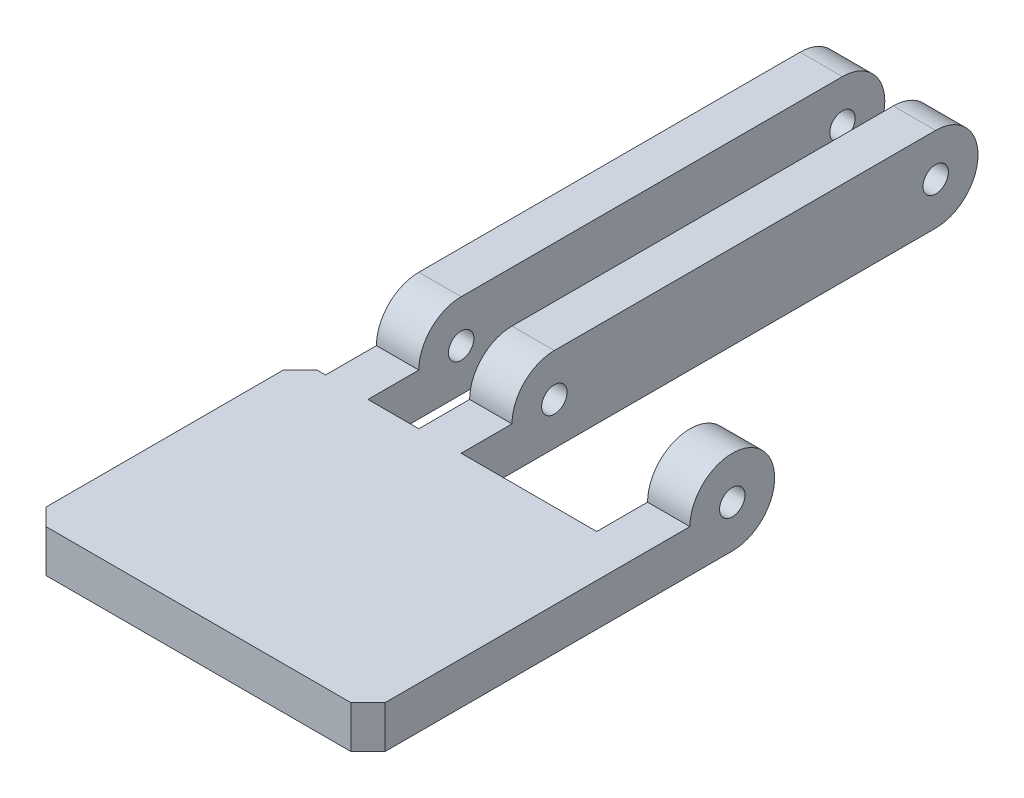
from build123d import *

# Parameters (mm, degrees)
SKETCH_1_W               = 50
SKETCH_1_H               = 43
EXTRUDE_1_DEPTH          = 5
SKETCH_3_R               = 5
EXTRUDE_2_DEPTH          = 5
EXTRUDE_START            = -6
EXTRUDE_3_DEPTH          = 5
EXTRUDE_4_DEPTH          = 5
SKETCH_9_R               = 1.5
CUT_EXTRUDE_2_DEPTH      = 11
CUT_EXTRUDE_2_DEPTH_BACK = 41
SKETCH_11_W              = 3
SKETCH_11_H              = 11
SKETCH_11_W_2            = 6
SKETCH_11_W_3            = 16
SKETCH_11_W_4            = 10
CUT_EXTRUDE_3_DEPTH      = 6
CUT_EXTRUDE_3_DEPTH_BACK = 6
SKETCH_12_R              = 1.5
CUT_EXTRUDE_4_DEPTH      = 32
CUT_EXTRUDE_4_DEPTH_BACK = 20
SKETCH_13_W              = 10
SKETCH_13_H              = 32
CUT_EXTRUDE_5_DEPTH      = 6
CUT_EXTRUDE_5_DEPTH_BACK = 6
CHAMFER_2_SIZE           = 2


with BuildPart() as part:
    # 草图1 → 凸台-拉伸1 (new body)
    with BuildSketch(Plane(origin=(0, 0, 0), x_dir=(1, 0, 0), z_dir=(0, 1, 0))):
        with Locations((0, -3.5)):
            Rectangle(SKETCH_1_W, SKETCH_1_H)
    extrude(amount=EXTRUDE_1_DEPTH)

    # 草图3 → 凸台-拉伸2 (add)
    with BuildSketch(Plane(origin=(15, 0, 0), x_dir=(0, 0, -1), z_dir=(1, 0, 0))):
        with Locations((18, 5)):
            Circle(SKETCH_3_R)
    extrude(amount=-EXTRUDE_2_DEPTH)

    # 草图5 → 凸台-拉伸3 (add)
    with BuildSketch(Plane(origin=(0, 0, 0), x_dir=(0, 0, -1), z_dir=(1, 0, 0)).offset(EXTRUDE_START)):
        with BuildLine():
            Line((18, 10), (63, 10))
            ThreePointArc((63, 10), (68, 5), (63, 0))
            Line((63, 0), (18, 0))
            ThreePointArc((18, 0), (13, 5), (18, 10))
        make_face()
    extrude(amount=-EXTRUDE_3_DEPTH)

    # 草图6 → 凸台-拉伸4 (add)
    with BuildSketch(Plane(origin=(-22, 0, 0), x_dir=(0, 0, -1), z_dir=(1, 0, 0))):
        with BuildLine():
            Line((18, 10), (63, 10))
            ThreePointArc((63, 10), (68, 5), (63, 0))
            Line((63, 0), (18, 0))
            ThreePointArc((18, 0), (13, 5), (18, 10))
        make_face()
    extrude(amount=EXTRUDE_4_DEPTH)

    # 草图9 → 切除-拉伸2 (cut, two sides)
    with BuildSketch(Plane(origin=(15, 0, 0), x_dir=(0, 0, -1), z_dir=(1, 0, 0))) as cut_extrude_2_sk:
        with Locations((18, 5)):
            Circle(SKETCH_9_R)
    extrude(amount=CUT_EXTRUDE_2_DEPTH, mode=Mode.SUBTRACT)
    extrude(cut_extrude_2_sk.sketch, amount=-CUT_EXTRUDE_2_DEPTH_BACK, mode=Mode.SUBTRACT)

    # 草图11 → 切除-拉伸3 (cut, two sides)
    with BuildSketch(Plane(origin=(0, 5, 0), x_dir=(1, 0, 0), z_dir=(0, 1, 0))) as cut_extrude_3_sk:
        with Locations((-23.5, 12.5)):
            Rectangle(SKETCH_11_W, SKETCH_11_H)
        with Locations((-14, 12.5)):
            Rectangle(SKETCH_11_W_2, SKETCH_11_H)
        with Locations((2, 12.5)):
            Rectangle(SKETCH_11_W_3, SKETCH_11_H)
        with Locations((20, 12.5)):
            Rectangle(SKETCH_11_W_4, SKETCH_11_H)
    extrude(amount=CUT_EXTRUDE_3_DEPTH, mode=Mode.SUBTRACT)
    extrude(cut_extrude_3_sk.sketch, amount=-CUT_EXTRUDE_3_DEPTH_BACK, mode=Mode.SUBTRACT)

    # 草图12 → 切除-拉伸4 (cut, two sides)
    with BuildSketch(Plane(origin=(-6, 0, 0), x_dir=(0, 0, -1), z_dir=(1, 0, 0))) as cut_extrude_4_sk:
        with Locations((63, 5)):
            Circle(SKETCH_12_R)
    extrude(amount=CUT_EXTRUDE_4_DEPTH, mode=Mode.SUBTRACT)
    extrude(cut_extrude_4_sk.sketch, amount=-CUT_EXTRUDE_4_DEPTH_BACK, mode=Mode.SUBTRACT)

    # 草图13 → 切除-拉伸5 (cut, two sides)
    with BuildSketch(Plane(origin=(0, 5, 0), x_dir=(1, 0, 0), z_dir=(0, 1, 0))) as cut_extrude_5_sk:
        with Locations((20, -9)):
            Rectangle(SKETCH_13_W, SKETCH_13_H)
    extrude(amount=CUT_EXTRUDE_5_DEPTH, mode=Mode.SUBTRACT)
    extrude(cut_extrude_5_sk.sketch, amount=-CUT_EXTRUDE_5_DEPTH_BACK, mode=Mode.SUBTRACT)

    # 倒角2
    chamfer_2_edges = [part.edges().sort_by_distance(p)[0] for p in [
        (-25, 2.5, -7),
        (15, 2.5, 25),
        (-25, 2.5, 25),
    ]]
    chamfer(chamfer_2_edges, length=CHAMFER_2_SIZE)


solid = part.part
